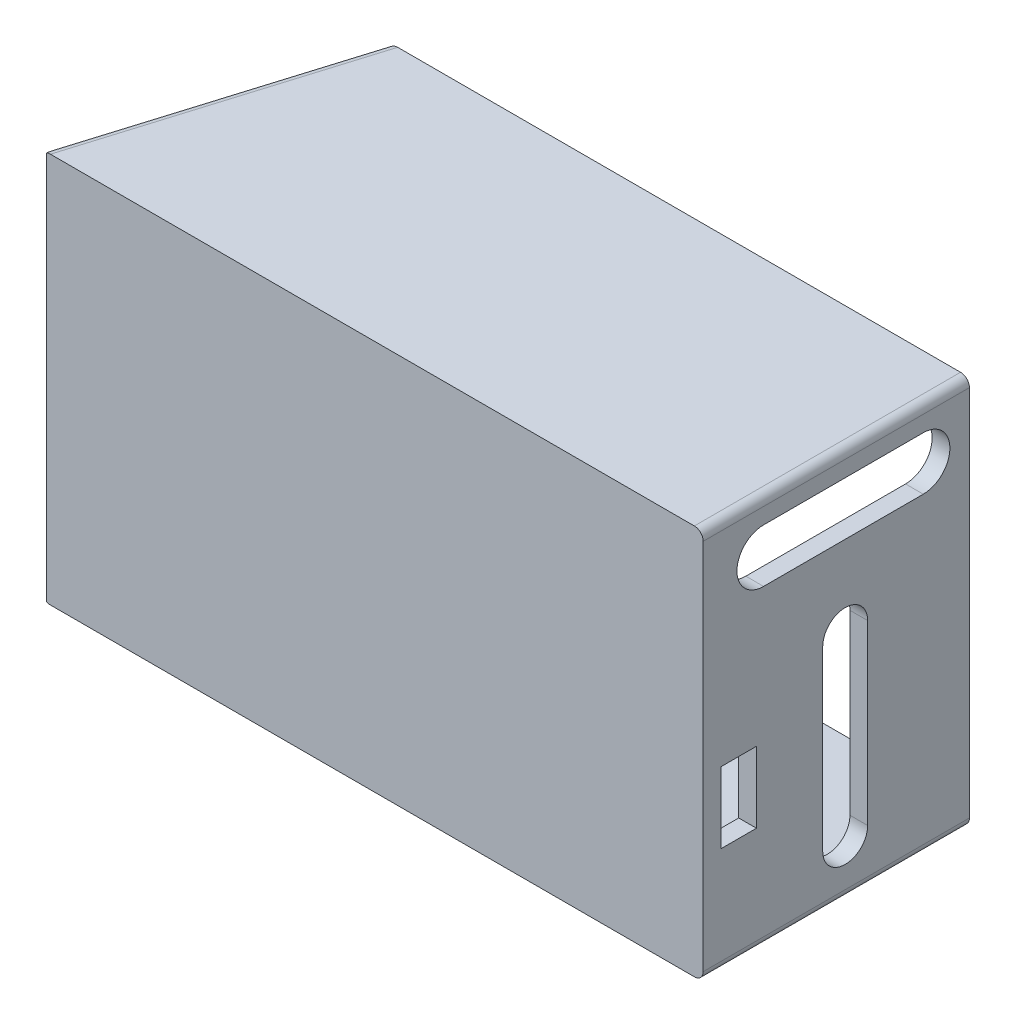
from build123d import *

# Parameters (mm, degrees)
ESQUISSE1_W             = 185
ESQUISSE1_H             = 110
BOSS_EXTRU_1_DEPTH      = 5
BOSS_EXTRU_2_DEPTH      = 110
BOSS_EXTRU_3_DEPTH      = 5
BOSS_EXTRU_4_DEPTH      = 5
ESQUISSE8_W             = 70
ESQUISSE8_H             = 100
BOSS_EXTRU_6_DEPTH      = 5
ESQUISSE10_R            = 2.5
ENL_V_MAT_EXTRU_1_DEPTH = 5
ESQUISSE13_R            = 1
ENL_V_MAT_EXTRU_2_DEPTH = 10
ESQUISSE15_W            = 10
ESQUISSE15_H            = 20
ENL_V_MAT_EXTRU_3_DEPTH = 10
ESQUISSE14_R            = 2.5
ENL_V_MAT_EXTRU_4_DEPTH = 10
CONG_2_R                = 2.5
CONG_3_R                = 2.5
CONG_4_R                = 2.5
CONG_5_R                = 2.5


with BuildPart() as part:
    # Esquisse1 → Boss.-Extru.1 (new body)
    with BuildSketch(Plane.XY):
        with Locations((-22.430690869, -9.25879397)):
            Rectangle(ESQUISSE1_W, ESQUISSE1_H)
    extrude(amount=BOSS_EXTRU_1_DEPTH)

    # Esquisse3 → Boss.-Extru.2 (add)
    with BuildSketch(Plane(origin=(0, 45.74120603, 0), x_dir=(1, 0, 0), z_dir=(0, 1, 0))):
        Polygon((-114.930690869, 0), (-93.616299119, 70), (-88.616299119, 70), (-109.930690869, 0), align=None)
    extrude(amount=-BOSS_EXTRU_2_DEPTH)

    # Esquisse4 → Boss.-Extru.3 (add)
    with BuildSketch(Plane(origin=(0, 45.74120603, 0), x_dir=(1, 0, 0), z_dir=(0, 1, 0))):
        Polygon((-109.930690869, 0), (-88.616299119, 70), (70.069309131, 70), (70.069309131, 0), align=None)
    extrude(amount=-BOSS_EXTRU_3_DEPTH)

    # Esquisse7 → Boss.-Extru.4 (add)
    with BuildSketch(Plane.XZ.offset(64.25879397)):
        Polygon((-109.930690869, 0), (-88.616299119, -70), (70.069309131, -70), (70.069309131, 0), align=None)
    extrude(amount=-BOSS_EXTRU_4_DEPTH)

    # Esquisse8 → Boss.-Extru.6 (add)
    with BuildSketch(Plane(origin=(70.069309131, 0, 0), x_dir=(0, 0, -1), z_dir=(1, 0, 0))):
        with Locations((35, -9.25879397)):
            Rectangle(ESQUISSE8_W, ESQUISSE8_H)
        with BuildLine():
            Line((41.331742872, 0.74120603), (41.331742872, -49.25879397))
            ThreePointArc((41.331742872, -49.25879397), (35, -55.590536842), (28.668257128, -49.25879397))
            Line((28.668257128, -49.25879397), (28.668257128, 0.74120603))
            ThreePointArc((28.668257128, 0.74120603), (35, 7.072948902), (41.331742872, 0.74120603))
        make_face(mode=Mode.SUBTRACT)
        with BuildLine():
            Line((12, 38.74120603), (57, 38.74120603))
            ThreePointArc((57, 38.74120603), (64.5, 31.24120603), (57, 23.74120603))
            Line((57, 23.74120603), (12, 23.74120603))
            ThreePointArc((12, 23.74120603), (4.5, 31.24120603), (12, 38.74120603))
        make_face(mode=Mode.SUBTRACT)
    extrude(amount=-BOSS_EXTRU_6_DEPTH)

    # Esquisse10 → Enlèv. mat.-Extru.1 (cut)
    with BuildSketch(Plane(origin=(-105.179022211, 0, -32.026098333), x_dir=(-0.291287239, 0, 0.956635638), z_dir=(-0.956635638, 0, -0.291287239))):
        with Locations((-8, 38.74120603)):
            Circle(ESQUISSE10_R)
        with Locations((-8, 30.74120603)):
            Circle(ESQUISSE10_R)
        with Locations((-8, 22.74120603)):
            Circle(ESQUISSE10_R)
        with Locations((-8, 14.74120603)):
            Circle(ESQUISSE10_R)
        with Locations((-8, 6.74120603)):
            Circle(ESQUISSE10_R)
        with Locations((-8, -1.25879397)):
            Circle(ESQUISSE10_R)
        with Locations((-8, -9.25879397)):
            Circle(ESQUISSE10_R)
        with Locations((-8, -17.25879397)):
            Circle(ESQUISSE10_R)
        with Locations((-8, -25.25879397)):
            Circle(ESQUISSE10_R)
        with Locations((-8, -33.25879397)):
            Circle(ESQUISSE10_R)
        with Locations((-8, -41.25879397)):
            Circle(ESQUISSE10_R)
        with Locations((-8, -49.25879397)):
            Circle(ESQUISSE10_R)
        with Locations((-8, -57.25879397)):
            Circle(ESQUISSE10_R)
        with Locations((-28, -57.25879397)):
            Circle(ESQUISSE10_R)
        with Locations((-28, -49.25879397)):
            Circle(ESQUISSE10_R)
        with Locations((-28, -41.25879397)):
            Circle(ESQUISSE10_R)
        with Locations((-28, -9.25879397)):
            Circle(ESQUISSE10_R)
        with Locations((-28, -17.25879397)):
            Circle(ESQUISSE10_R)
        with Locations((-28, -25.25879397)):
            Circle(ESQUISSE10_R)
        with Locations((-28, -33.25879397)):
            Circle(ESQUISSE10_R)
        with Locations((-28, -1.25879397)):
            Circle(ESQUISSE10_R)
        with Locations((-28, 6.74120603)):
            Circle(ESQUISSE10_R)
        with Locations((-28, 14.74120603)):
            Circle(ESQUISSE10_R)
        with Locations((-28, 22.74120603)):
            Circle(ESQUISSE10_R)
        with Locations((-28, 30.74120603)):
            Circle(ESQUISSE10_R)
        with Locations((-28, 38.74120603)):
            Circle(ESQUISSE10_R)
    extrude(amount=-ENL_V_MAT_EXTRU_1_DEPTH, mode=Mode.SUBTRACT)

    # Esquisse13 → Enlèv. mat.-Extru.2 (cut)
    with BuildSketch(Plane(origin=(0, 0, -70), x_dir=(-1, 0, 0), z_dir=(0, 0, -1))):
        with Locations((-67.069309131, 42.74120603)):
            Circle(ESQUISSE13_R)
        with Locations((-67.069309131, -61.25879397)):
            Circle(ESQUISSE13_R)
        with Locations((90.616299119, -61.25879397)):
            Circle(ESQUISSE13_R)
        with Locations((90.616299119, 42.74120603)):
            Circle(ESQUISSE13_R)
    extrude(amount=-ENL_V_MAT_EXTRU_2_DEPTH, mode=Mode.SUBTRACT)

    # Esquisse15 → Enlèv. mat.-Extru.3 (cut)
    with BuildSketch(Plane(origin=(70.069309131, 0, 0), x_dir=(0, 0, -1), z_dir=(1, 0, 0))):
        with Locations((5, -24.25879397)):
            Rectangle(ESQUISSE15_W, ESQUISSE15_H)
    extrude(amount=-ENL_V_MAT_EXTRU_3_DEPTH, mode=Mode.SUBTRACT)

    # Esquisse14 → Enlèv. mat.-Extru.4 (cut)
    with BuildSketch(Plane(origin=(0, -64.25879397, 0), x_dir=(-1, 0, 0), z_dir=(0, -1, 0))):
        with Locations((-60.069309131, 60)):
            Circle(ESQUISSE14_R)
    extrude(amount=-ENL_V_MAT_EXTRU_4_DEPTH, mode=Mode.SUBTRACT)

    # Congé2
    cong_2_edges = [part.edges().sort_by_distance(p)[0] for p in [
        (-104.273494994, -64.25879397, -35),
    ]]
    fillet(cong_2_edges, radius=CONG_2_R)

    # Congé3
    cong_3_edges = [part.edges().sort_by_distance(p)[0] for p in [
        (-104.273494994, 45.74120603, -35),
    ]]
    fillet(cong_3_edges, radius=CONG_3_R)

    # Congé4
    cong_4_edges = [part.edges().sort_by_distance(p)[0] for p in [
        (70.069309131, -64.25879397, -32.5),
    ]]
    fillet(cong_4_edges, radius=CONG_4_R)

    # Congé5
    cong_5_edges = [part.edges().sort_by_distance(p)[0] for p in [
        (70.069309131, 45.74120603, -32.5),
    ]]
    fillet(cong_5_edges, radius=CONG_5_R)


solid = part.part
